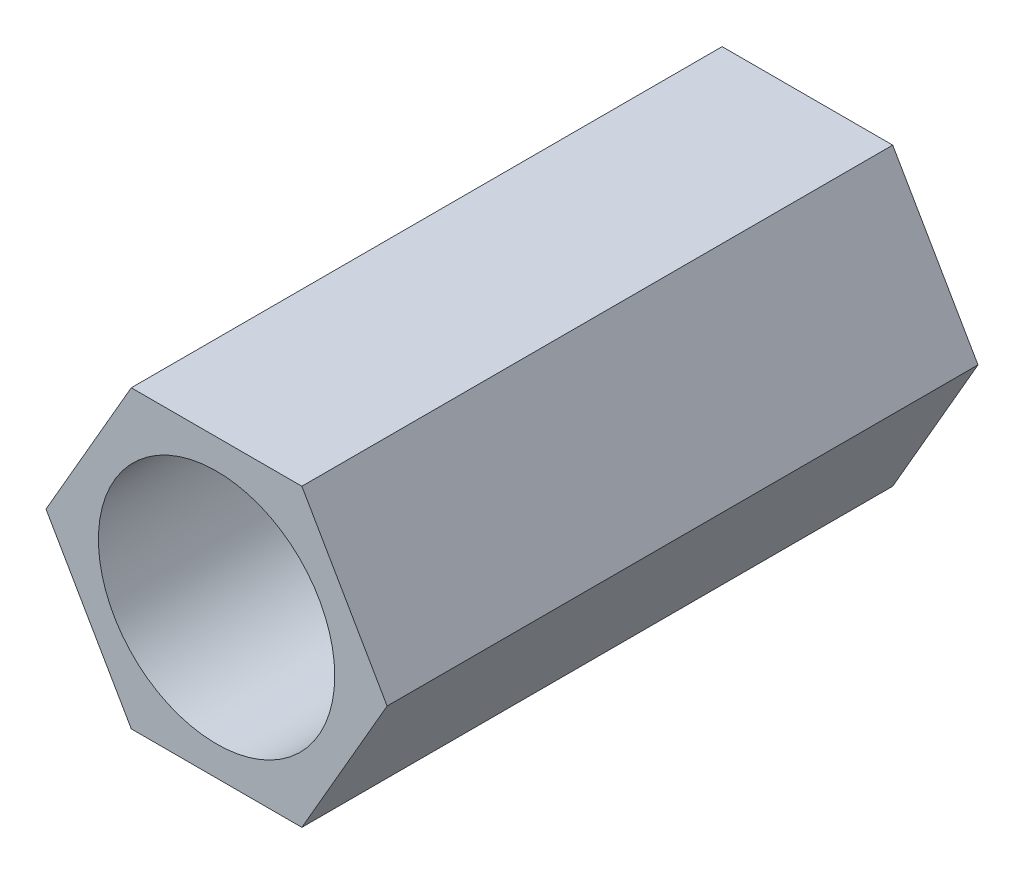
from build123d import *

# Parameters (mm, degrees)
EXTRUDE_1_DEPTH     = 20
SKETCH_2_R          = 4
CUT_EXTRUDE_1_DEPTH = 20


with BuildPart() as part:
    # 草图1 → 凸台-拉伸1 (new body)
    with BuildSketch(Plane.XY):
        Polygon((5.773502692, 0), (2.886751346, 5), (-2.886751346, 5), (-5.773502692, 0), (-2.886751346, -5), (2.886751346, -5), align=None)
    extrude(amount=EXTRUDE_1_DEPTH)

    # 草图2 → 切除-拉伸1 (cut)
    with BuildSketch(Plane.XY.offset(20)):
        Circle(SKETCH_2_R)
    extrude(amount=-CUT_EXTRUDE_1_DEPTH, mode=Mode.SUBTRACT)


solid = part.part
